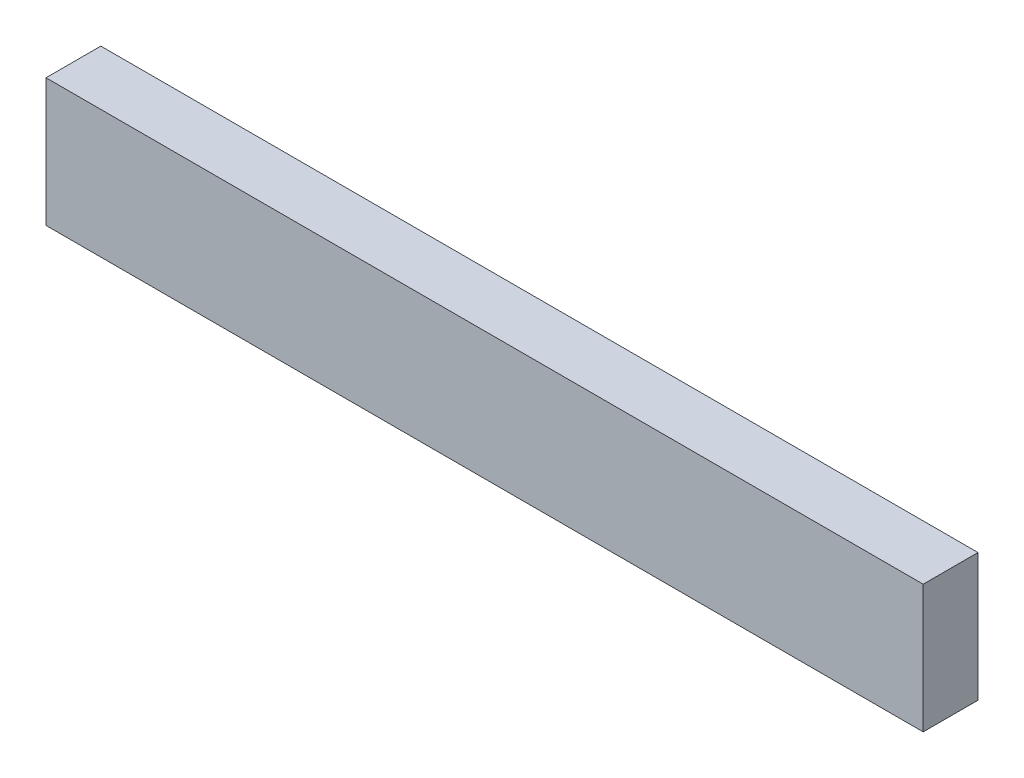
from build123d import *

# Parameters (mm, degrees)
BOSS_EXTRUDE1_DEPTH      = 304.8
BOSS_EXTRUDE1_DEPTH_BACK = 304.8
SKETCH3_W                = 38.1
SKETCH3_H                = 88.9


with BuildPart() as part:
    # Sketch3 → Boss-Extrude1 (new, two sides: drawn at the far end of the back side and taken through both)
    with BuildSketch(Plane(origin=(0, 0, 0), x_dir=(0, 0, -1), z_dir=(1, 0, 0)).offset(-BOSS_EXTRUDE1_DEPTH_BACK)):
        Rectangle(SKETCH3_W, SKETCH3_H)
    extrude(amount=BOSS_EXTRUDE1_DEPTH + BOSS_EXTRUDE1_DEPTH_BACK)


solid = part.part
